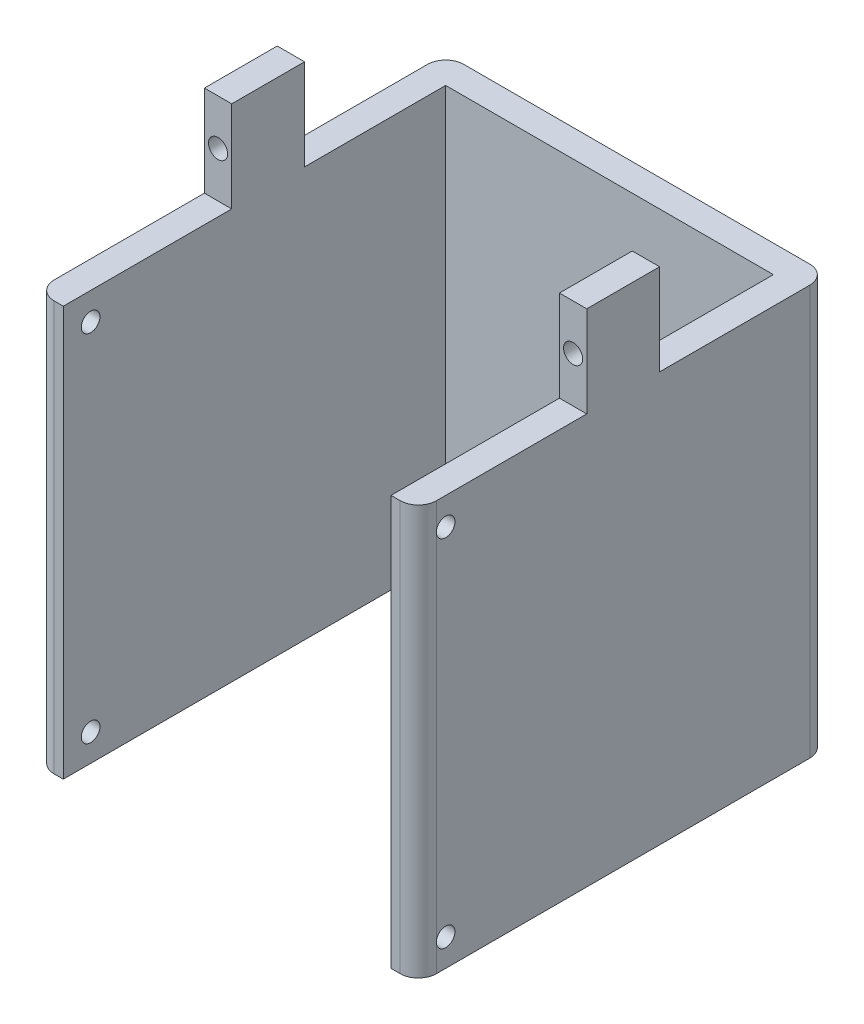
from build123d import *

# Parameters (mm, degrees)
EXTRUDE_1_DEPTH      = 40
EXTRUDE_1_DEPTH_BACK = 5
SKETCH_2_W           = 36
SKETCH_2_H           = 37
CUT_EXTRUDE_1_DEPTH  = 50
SKETCH_5_W           = 36
SKETCH_5_H           = 5
CUT_EXTRUDE_4_DEPTH  = 43
SKETCH_9_R           = 1.025
CUT_EXTRUDE_5_DEPTH  = 45.5
SKETCH_10_W          = 3
SKETCH_10_H          = 8
EXTRUDE_4_DEPTH      = 10
SKETCH_12_R          = 1.05
CUT_EXTRUDE_6_DEPTH  = 10
FILLET_4_R           = 2
FILLET_5_R           = 2
FILLET_6_R           = 2
FILLET_7_R           = 2


with BuildPart() as part:
    # 草圖1 → 填料-伸長1 (new body, two sides)
    with BuildSketch(Plane.XY) as extrude_1_sk:
        Polygon((-14.545454545, -28.090909091), (-15.545454545, -28.090909091), (-15.545454545, 16.909090909), (-14.545454545, 16.909090909), (25.454545455, 16.909090909), (26.454545455, 16.909090909), (26.454545455, -28.090909091), (25.454545455, -28.090909091), align=None)
    extrude(amount=EXTRUDE_1_DEPTH)
    extrude(extrude_1_sk.sketch, amount=-EXTRUDE_1_DEPTH_BACK)

    # 草圖2 → 除料-伸長1 (cut)
    with BuildSketch(Plane(origin=(0, 16.909090909, 0), x_dir=(1, 0, 0), z_dir=(0, 1, 0))):
        with Locations((5.454545455, -21.5)):
            Rectangle(SKETCH_2_W, SKETCH_2_H)
    extrude(amount=-CUT_EXTRUDE_1_DEPTH, mode=Mode.SUBTRACT)

    # 草圖5 → 除料-伸長4 (cut)
    with BuildSketch(Plane(origin=(0, 16.909090909, 0), x_dir=(1, 0, 0), z_dir=(0, 1, 0))):
        with Locations((5.454545455, -0.5)):
            Rectangle(SKETCH_5_W, SKETCH_5_H)
    extrude(amount=-CUT_EXTRUDE_4_DEPTH, mode=Mode.SUBTRACT)

    # 草圖9 → 除料-伸長5 (cut)
    with BuildSketch(Plane.ZY.offset(15.545454545)):
        with Locations((37, -25.090909091)):
            Circle(SKETCH_9_R)
        with Locations((37, 13.909090909)):
            Circle(SKETCH_9_R)
    extrude(amount=-CUT_EXTRUDE_5_DEPTH, mode=Mode.SUBTRACT)

    # 草圖10 → 填料-伸長4 (add)
    with BuildSketch(Plane(origin=(0, 16.909090909, 0), x_dir=(1, 0, 0), z_dir=(0, 1, 0))):
        with Locations((-14.045454545, -17.5)):
            Rectangle(SKETCH_10_W, SKETCH_10_H)
        with Locations((24.954545455, -17.5)):
            Rectangle(SKETCH_10_W, SKETCH_10_H)
    extrude(amount=EXTRUDE_4_DEPTH)

    # 草圖12 → 除料-伸長6 (cut)
    with BuildSketch(Plane(origin=(0, 0, 13.5), x_dir=(-1, 0, 0), z_dir=(0, 0, -1))):
        with Locations((-24.954545455, 21.909090909)):
            Circle(SKETCH_12_R)
        with Locations((14.045454545, 21.909090909)):
            Circle(SKETCH_12_R)
    extrude(amount=-CUT_EXTRUDE_6_DEPTH, mode=Mode.SUBTRACT)

    # 圓角4
    fillet_4_edges = [part.edges().sort_by_distance(p)[0] for p in [
        (26.454545455, -5.590909091, -5),
    ]]
    fillet(fillet_4_edges, radius=FILLET_4_R)

    # 圓角5
    fillet_5_edges = [part.edges().sort_by_distance(p)[0] for p in [
        (-15.545454545, -5.590909091, -5),
    ]]
    fillet(fillet_5_edges, radius=FILLET_5_R)

    # 圓角6
    fillet_6_edges = [part.edges().sort_by_distance(p)[0] for p in [
        (26.454545455, -5.590909091, 40),
    ]]
    fillet(fillet_6_edges, radius=FILLET_6_R)

    # 圓角7
    fillet_7_edges = [part.edges().sort_by_distance(p)[0] for p in [
        (-15.545454545, -5.590909091, 40),
    ]]
    fillet(fillet_7_edges, radius=FILLET_7_R)


solid = part.part
